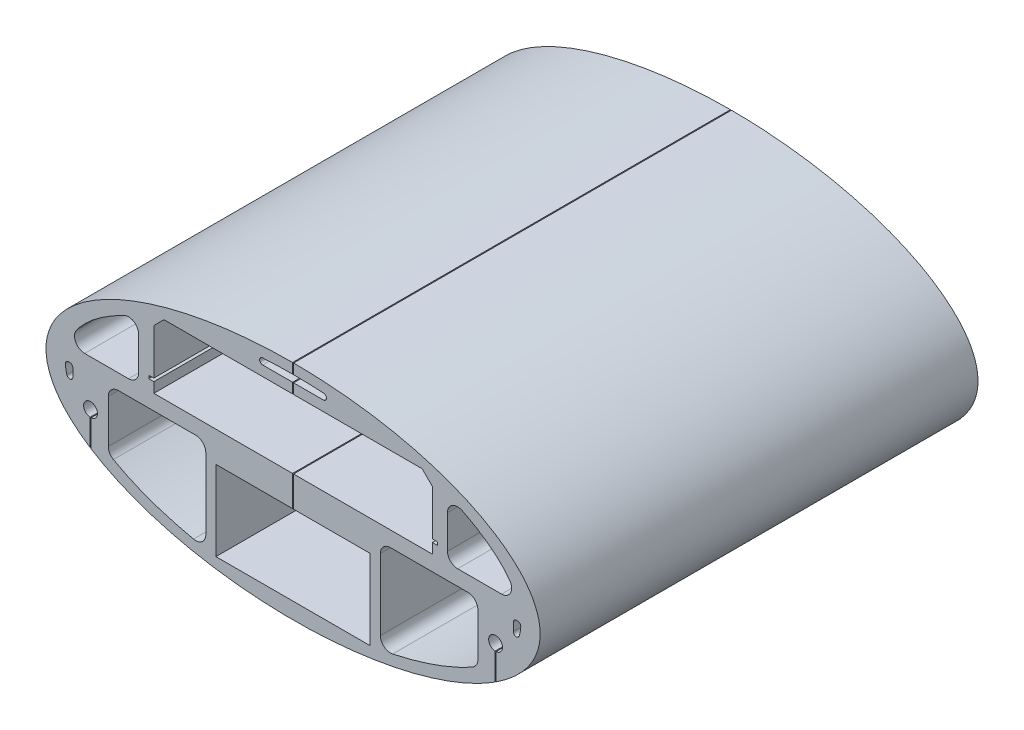
from build123d import *

# Parameters (mm, degrees)
SKETCH1_RX               = 244
SKETCH1_RY               = 110
BOSS_EXTRUDE1_DEPTH      = 432.44
CUT_EXTRUDE5_DEPTH       = 433.44
SKETCH13_W               = 152.4
SKETCH13_H               = 78.9
CUT_EXTRUDE7_DEPTH       = 433.44
SKETCH12_R               = 6.83635542
CUT_EXTRUDE8_DEPTH       = 433.44
SKETCH14_W               = 1
SKETCH14_H               = 33.332943991
SKETCH14_H_2             = 125
CUT_EXTRUDE9_DEPTH       = 1
CUT_EXTRUDE9_DEPTH_BACK  = 433.44
CUT_EXTRUDE10_DEPTH      = 1.0000001
CUT_EXTRUDE10_DEPTH_BACK = 433.4400001
FILLET1_R                = 10
FILLET2_R                = 10
FILLET3_R                = 3
FILLET4_R                = 3
CHAMFER1_SIZE            = 10


with BuildPart() as part:
    # Sketch1 → Boss-Extrude1 (new body)
    with BuildSketch(Plane.XY):
        with Locations((0, 0)):
            Ellipse(SKETCH1_RX, SKETCH1_RY)
    extrude(amount=-BOSS_EXTRUDE1_DEPTH)

    # Sketch10 → Cut-Extrude5 (cut, through all)
    with BuildSketch(Plane.XY):
        Polygon((-137.5, 83.1), (137.5, 83.1), (137.5, 28.1), (142.5, 28.1), (142.5, 25.1), (137.5, 25.1), (137.5, 15.1), (-137.5, 15.1), (-137.5, 25.1), (-142.5, 25.1), (-142.5, 28.1), (-137.5, 28.1), align=None)
    extrude(amount=-CUT_EXTRUDE5_DEPTH, mode=Mode.SUBTRACT)

    # Sketch13 → Cut-Extrude7 (cut, through all)
    with BuildSketch(Plane.XY):
        with Locations((0, -54.45)):
            Rectangle(SKETCH13_W, SKETCH13_H)
    extrude(amount=-CUT_EXTRUDE7_DEPTH, mode=Mode.SUBTRACT)

    # Sketch12 → Cut-Extrude8 (cut, through all)
    with BuildSketch(Plane.XY):
        with Locations((200, -30)):
            Circle(SKETCH12_R)
        with Locations((-200, -30)):
            Circle(SKETCH12_R)
    extrude(amount=-CUT_EXTRUDE8_DEPTH, mode=Mode.SUBTRACT)

    # Sketch14 → Cut-Extrude9 (cut, two sides)
    with BuildSketch(Plane.XY) as cut_extrude9_sk:
        with Locations((200, -46.666471996)):
            Rectangle(SKETCH14_W, SKETCH14_H)
        with Locations((-200, -46.666471996)):
            Rectangle(SKETCH14_W, SKETCH14_H)
        with Locations((0, 47.5)):
            Rectangle(SKETCH14_W, SKETCH14_H_2)
    extrude(amount=CUT_EXTRUDE9_DEPTH, mode=Mode.SUBTRACT)
    extrude(cut_extrude9_sk.sketch, amount=-CUT_EXTRUDE9_DEPTH_BACK, mode=Mode.SUBTRACT)

    # Sketch15 → Cut-Extrude10 (cut, two sides)
    with BuildSketch(Plane.XY) as cut_extrude10_sk:
        with BuildLine():
            Line((152.5, 73.52668114), (152.5, 15.1))
            Line((152.5, 15.1), (222.420096608, 15.1))
            add(Edge.make_bspline(
                [(222.420096608, 15.1), (210.507279325, 49.76143368), (152.5, 73.52668114)],
                knots=[3.293172448, 3.293172448, 3.293172448, 3.967652907, 3.967652907, 3.967652907], degree=2, weights=[1, 0.943671422, 1]))
        make_face()
        with BuildLine():
            Line((86.2, -92.370226618), (86.2, 0))
            Line((86.2, 0), (182.5, 0))
            Line((182.5, 0), (182.5, -58.489209726))
            add(Edge.make_bspline(
                [(86.2, -92.370226618), (145.163847664, -81.501065263), (182.5, -58.489209726)],
                knots=[1.963958369, 1.963958369, 1.963958369, 2.516845633, 2.516845633, 2.516845633], degree=2, weights=[1, 0.962032181, 1]))
        make_face()
        with BuildLine():
            Line((217.5, -25.60381916), (217.5, 0))
            Line((217.5, 0), (225, 0))
            add(Edge.make_bspline(
                [(217.5, -25.60381916), (225, -13.018891098), (225, 0)],
                knots=[2.882671112, 2.882671112, 2.882671112, 3.141592654, 3.141592654, 3.141592654], degree=2, weights=[1, 0.991631652, 1]))
        make_face()
        with BuildLine():
            Line((-82.129314955, 93.1), (82.129314955, 93.1))
            add(Edge.make_bspline(
                [(82.129314955, 93.1), (0, 107.411385607), (-82.129314955, 93.1)],
                knots=[4.338735578, 4.338735578, 4.338735578, 5.086042382, 5.086042382, 5.086042382], degree=2, weights=[1, 0.931, 1]))
        make_face()
        with BuildLine():
            Line((-86.2, -92.370226618), (-86.2, 0))
            Line((-86.2, 0), (-182.5, 0))
            Line((-182.5, 0), (-182.5, -58.489209726))
            add(Edge.make_bspline(
                [(-182.5, -58.489209726), (-145.163847664, -81.501065263), (-86.2, -92.370226618)],
                knots=[0.624747021, 0.624747021, 0.624747021, 1.177634285, 1.177634285, 1.177634285], degree=2, weights=[1, 0.962032181, 1]))
        make_face()
        with BuildLine():
            Line((-217.5, -25.60381916), (-217.5, 0))
            Line((-217.5, 0), (-225, 0))
            add(Edge.make_bspline(
                [(-225, 0), (-225, -13.018891098), (-217.5, -25.60381916)],
                knots=[0, 0, 0, 0.258921542, 0.258921542, 0.258921542], degree=2, weights=[1, 0.991631652, 1]))
        make_face()
        with BuildLine():
            Line((-152.5, 15.1), (-222.420096608, 15.1))
            add(Edge.make_bspline(
                [(-152.5, 73.52668114), (-210.507279325, 49.76143368), (-222.420096608, 15.1)],
                knots=[5.457125054, 5.457125054, 5.457125054, 6.131605513, 6.131605513, 6.131605513], degree=2, weights=[1, 0.943671422, 1]))
            Line((-152.5, 73.52668114), (-152.5, 15.1))
        make_face()
    extrude(amount=CUT_EXTRUDE10_DEPTH, mode=Mode.SUBTRACT)
    extrude(cut_extrude10_sk.sketch, amount=-CUT_EXTRUDE10_DEPTH_BACK, mode=Mode.SUBTRACT)

    # Fillet1
    fillet1_edges = [part.edges().sort_by_distance(p)[0] for p in [
        (222.420096608, 15.1, -216.22),
        (152.5, 73.52668114, -216.22),
        (-222.420096608, 15.1, -216.22),
        (-152.5, 73.52668114, -216.22),
    ]]
    fillet(fillet1_edges, radius=FILLET1_R)

    # Fillet2
    fillet2_edges = [part.edges().sort_by_distance(p)[0] for p in [
        (152.5, 15.1, -216.22),
        (-152.5, 15.1, -216.22),
        (182.5, -58.489209726, -216.22),
        (86.2, 0, -216.22),
        (182.5, 0, -216.22),
        (-182.5, -58.489209726, -216.22),
        (-86.2, 0, -216.22),
        (-182.5, 0, -216.22),
        (86.2, -92.370226618, -216.22),
        (-86.2, -92.370226618, -216.22),
    ]]
    fillet(fillet2_edges, radius=FILLET2_R)

    # Fillet3
    fillet3_edges = [part.edges().sort_by_distance(p)[0] for p in [
        (217.5, -25.60381916, -216.22),
        (217.5, 0, -216.22),
        (225, 0, -216.22),
        (-217.5, 0, -216.22),
        (-217.5, -25.60381916, -216.22),
        (-225, 0, -216.22),
    ]]
    fillet(fillet3_edges, radius=FILLET3_R)

    # Fillet4
    fillet4_edges = [part.edges().sort_by_distance(p)[0] for p in [
        (-82.129314955, 93.1, -216.22),
        (82.129314955, 93.1, -216.22),
    ]]
    fillet(fillet4_edges, radius=FILLET4_R)

    # Chamfer1
    chamfer1_edges = [part.edges().sort_by_distance(p)[0] for p in [
        (-137.5, 83.1, -216.22),
        (137.5, 83.1, -216.22),
    ]]
    chamfer(chamfer1_edges, length=CHAMFER1_SIZE)


solid = part.part
